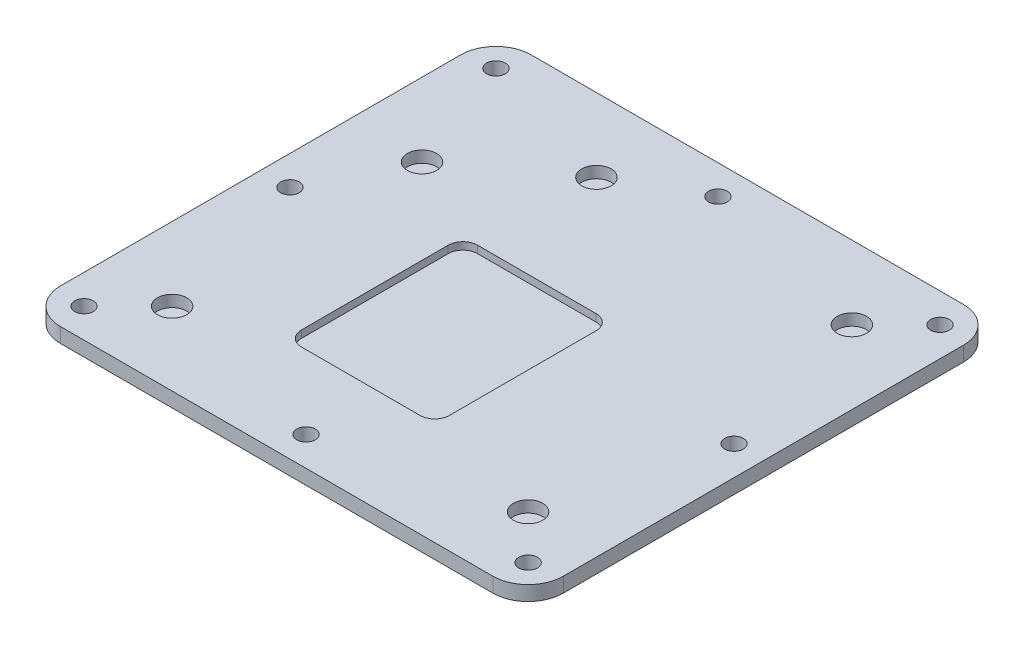
from build123d import *

# Parameters (mm, degrees)
SKETCH1_W              = 108.712
SKETCH1_H              = 101.7524
BOSS_EXTRUDE1_DEPTH    = 3.175
SKETCH1_4_W            = 32.004
SKETCH1_4_H            = 38.1
CUT_EXTRUDE1_DEPTH     = 1.5875
SKETCH4_R              = 3.175
CUT_EXTRUDE2_DEPTH     = 2.5
FILLET1_R              = 7.62
F_10_32_TAPPED_HOLE1_D = 4.0386
FILLET2_R              = 3.175


with BuildPart() as part:
    # Sketch1 → Boss-Extrude1 (new body)
    with BuildSketch(Plane(origin=(0, 0, 0), x_dir=(1, 0, 0), z_dir=(0, 1, 0))):
        Rectangle(SKETCH1_W, SKETCH1_H)
    extrude(amount=-BOSS_EXTRUDE1_DEPTH)

    # Sketch1_4 → Cut-Extrude1 (cut)
    with BuildSketch(Plane(origin=(0, 0, 0), x_dir=(1, 0, 0), z_dir=(0, 1, 0))):
        with Locations((-4.064, -9.6012)):
            Rectangle(SKETCH1_4_W, SKETCH1_4_H)
    extrude(amount=-CUT_EXTRUDE1_DEPTH, mode=Mode.SUBTRACT)

    # Sketch4 → Cut-Extrude2 (cut)
    with BuildSketch(Plane(origin=(0, 0, 0), x_dir=(1, 0, 0), z_dir=(0, 1, 0))):
        with Locations((-38.481, 19.0246)):
            Circle(SKETCH4_R)
        with Locations((-16.7386, 35.0012)):
            Circle(SKETCH4_R)
        with Locations((38.481, 35.0012)):
            Circle(SKETCH4_R)
        with Locations((38.481, -35.0012)):
            Circle(SKETCH4_R)
        with Locations((-38.481, -35.0012)):
            Circle(SKETCH4_R)
    extrude(amount=-CUT_EXTRUDE2_DEPTH, mode=Mode.SUBTRACT)

    # Fillet1
    fillet1_edges = [part.edges().sort_by_distance(p)[0] for p in [
        (-54.356, -1.5875, -50.8762),
        (54.356, -1.5875, -50.8762),
        (54.356, -1.5875, 50.8762),
        (-54.356, -1.5875, 50.8762),
    ]]
    fillet(fillet1_edges, radius=FILLET1_R)

    # 10-32 Tapped Hole1 (through all)
    with Locations(Plane(origin=(0, 0, 0), x_dir=(1, 0, 0), z_dir=(0, 1, 0))):
        with Locations((-48.006, 44.5262), (48.006, 44.5262), (48.006, -44.5262), (-48.006, -44.5262), (0, -44.5262), (-48.006, 0), (48.006, 0), (0, 44.5262)):
            Hole(F_10_32_TAPPED_HOLE1_D / 2)

    # Fillet2
    fillet2_edges = [part.edges().sort_by_distance(p)[0] for p in [
        (-20.066, -0.79375, -9.4488),
        (11.938, -0.79375, -9.4488),
        (11.938, -0.79375, 28.6512),
        (-20.066, -0.79375, 28.6512),
    ]]
    fillet(fillet2_edges, radius=FILLET2_R)


solid = part.part
